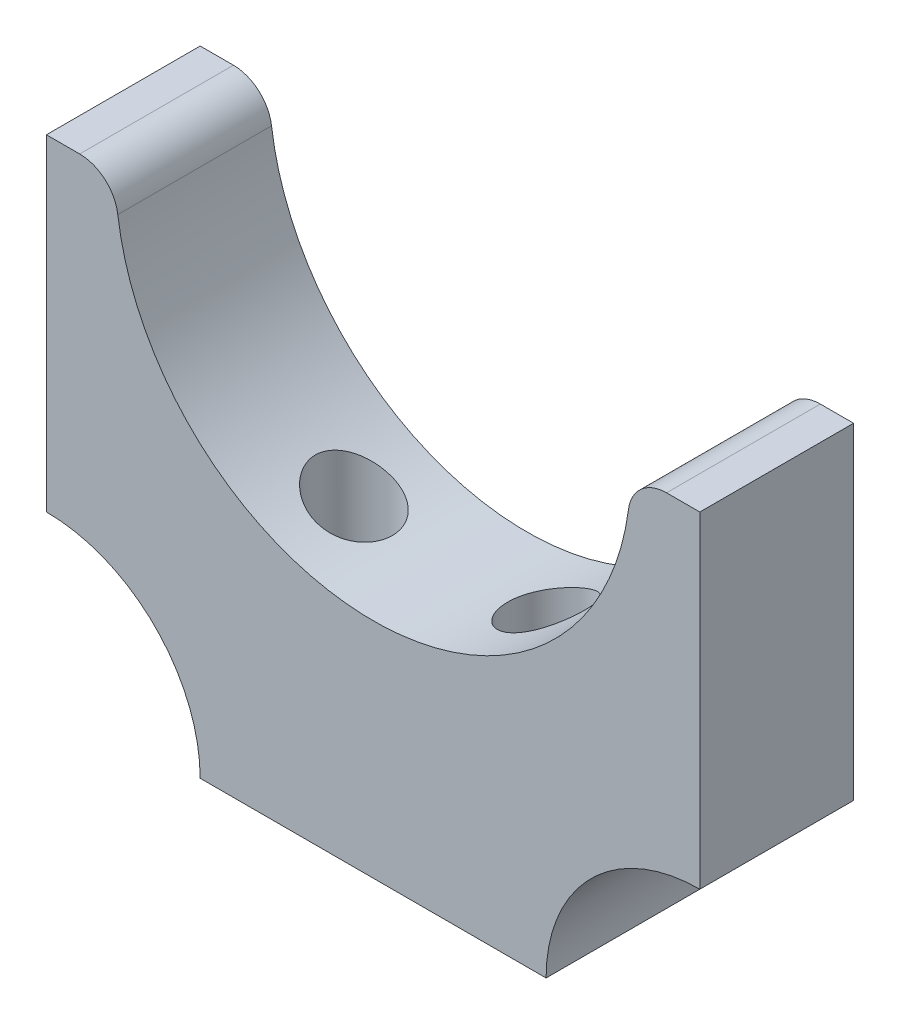
from build123d import *

# Parameters (mm, degrees)
BOSS_EXTRU_1_DEPTH      = 8
ENL_V_MAT_EXTRU_1_REACH = 27
ESQUISSE2_R             = 2
CHANFREIN1_SIZE         = 1
CONG_1_R                = 2


with BuildPart() as part:
    # Esquisse1 → Boss.-Extru.1 (new body)
    with BuildSketch(Plane.XY):
        with BuildLine():
            Line((-17, 12.5), (-17, -4.5))
            ThreePointArc((-17, -4.5), (-11.343145751, -6.843145751), (-9, -12.5))
            Line((-9, -12.5), (9, -12.5))
            ThreePointArc((9, -12.5), (11.343145751, -6.843145751), (17, -4.5))
            Line((17, -4.5), (17, 12.5))
            Line((17, 12.5), (13.4, 12.5))
            ThreePointArc((13.4, 12.5), (0, -0.9), (-13.4, 12.5))
            Line((-13.4, 12.5), (-17, 12.5))
        make_face()
    extrude(amount=BOSS_EXTRU_1_DEPTH)

    # Esquisse2 → Enlèv. mat.-Extru.1 (cut, up to next)
    with BuildSketch(Plane.XZ.offset(12.5), mode=Mode.PRIVATE) as enl_v_mat_extru_1_sk1:
        with Locations((-5, 4)):
            Circle(ESQUISSE2_R)
    enl_v_mat_extru_1_tool1 = extrude(enl_v_mat_extru_1_sk1.sketch, amount=-ENL_V_MAT_EXTRU_1_REACH, mode=Mode.PRIVATE) & part.part
    add(enl_v_mat_extru_1_tool1.solids().sort_by_distance((-5, -12.5, 4))[0], mode=Mode.SUBTRACT)
    # Esquisse2 → Enlèv. mat.-Extru.1 (cut, up to next)
    with BuildSketch(Plane.XZ.offset(12.5), mode=Mode.PRIVATE) as enl_v_mat_extru_1_sk2:
        with Locations((5, 4)):
            Circle(ESQUISSE2_R)
    enl_v_mat_extru_1_tool2 = extrude(enl_v_mat_extru_1_sk2.sketch, amount=-ENL_V_MAT_EXTRU_1_REACH, mode=Mode.PRIVATE) & part.part
    add(enl_v_mat_extru_1_tool2.solids().sort_by_distance((5, -12.5, 4))[0], mode=Mode.SUBTRACT)

    # Chanfrein1
    chanfrein1_edges = [part.edges().sort_by_distance(p)[0] for p in [
        (-7, -12.5, 4),
        (3, -12.5, 4),
    ]]
    chamfer(chanfrein1_edges, length=CHANFREIN1_SIZE)

    # Congé1
    cong_1_edges = [part.edges().sort_by_distance(p)[0] for p in [
        (-13.4, 12.5, 4),
        (13.4, 12.5, 4),
    ]]
    fillet(cong_1_edges, radius=CONG_1_R)


solid = part.part
